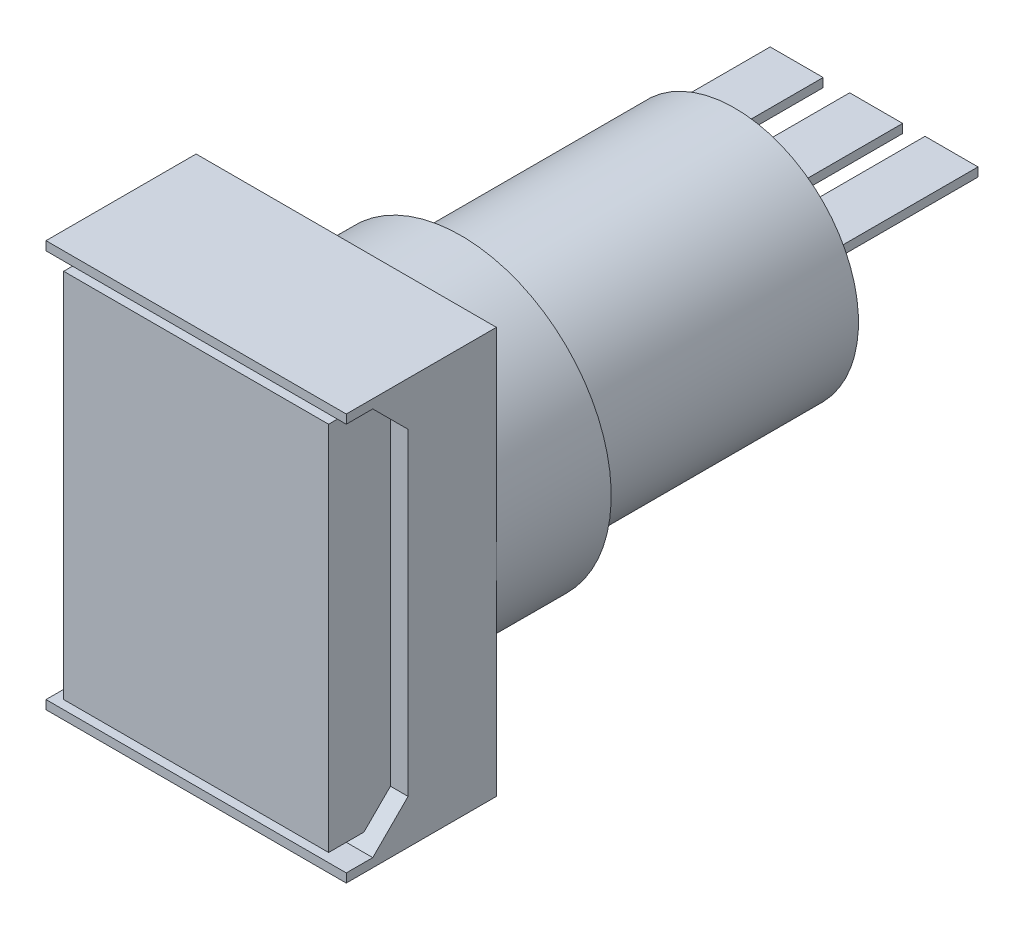
from build123d import *

# Parameters (mm, degrees)
SKETCH_1_W          = 17
SKETCH_1_H          = 23
EXTRUDE_1_DEPTH     = 8.5
CUT_EXTRUDE_1_DEPTH = 20
SKETCH_3_W          = 15
SKETCH_3_H          = 21
EXTRUDE_2_DEPTH     = 3.5
SKETCH_4_R          = 8.5
EXTRUDE_3_DEPTH     = 6.5
SKETCH_5_R          = 7
EXTRUDE_4_DEPTH     = 22
SKETCH_6_W          = 3
SKETCH_6_H          = 0.5
EXTRUDE_5_DEPTH     = 8
SKETCH_7_R          = 6.5
EXTRUDE_6_DEPTH     = 0.01


with BuildPart() as part:
    # ｽｹｯﾁ1 → ﾎﾞｽ - 押し出し1 (new body)
    with BuildSketch(Plane.XY):
        Rectangle(SKETCH_1_W, SKETCH_1_H)
    extrude(amount=EXTRUDE_1_DEPTH)

    # ｽｹｯﾁ2 → ｶｯﾄ - 押し出し1 (cut)
    with BuildSketch(Plane(origin=(8.5, 0, 0), x_dir=(0, 0, -1), z_dir=(1, 0, 0))):
        Polygon((-8.5, 11), (-7, 11), (-5, 9), (-5, -9), (-7, -11), (-8.5, -11), align=None)
    extrude(amount=-CUT_EXTRUDE_1_DEPTH, mode=Mode.SUBTRACT)

    # ｽｹｯﾁ3 → ﾎﾞｽ - 押し出し2 (add)
    with BuildSketch(Plane.XY.offset(5)):
        Rectangle(SKETCH_3_W, SKETCH_3_H)
    extrude(amount=EXTRUDE_2_DEPTH)

    # ｽｹｯﾁ4 → ﾎﾞｽ - 押し出し3 (add)
    with BuildSketch(Plane(origin=(0, 0, 0), x_dir=(-1, 0, 0), z_dir=(0, 0, -1))):
        Circle(SKETCH_4_R)
    extrude(amount=EXTRUDE_3_DEPTH)

    # ｽｹｯﾁ5 → ﾎﾞｽ - 押し出し4 (add)
    with BuildSketch(Plane(origin=(0, 0, 0), x_dir=(-1, 0, 0), z_dir=(0, 0, -1))):
        Circle(SKETCH_5_R)
    extrude(amount=EXTRUDE_4_DEPTH)

    # ｽｹｯﾁ6 → ﾎﾞｽ - 押し出し5 (add)
    with BuildSketch(Plane(origin=(0, 0, -22), x_dir=(-1, 0, 0), z_dir=(0, 0, -1))):
        with Locations((-4.266281297, 2.75)):
            Rectangle(SKETCH_6_W, SKETCH_6_H)
        with Locations((0, 2.75)):
            Rectangle(SKETCH_6_W, SKETCH_6_H)
        with Locations((4.5, 2.75)):
            Rectangle(SKETCH_6_W, SKETCH_6_H)
    extrude(amount=EXTRUDE_5_DEPTH)

    # ｽｹｯﾁ7 → ﾎﾞｽ - 押し出し6 (add)
    with BuildSketch(Plane(origin=(0, 0, -22), x_dir=(-1, 0, 0), z_dir=(0, 0, -1))):
        Circle(SKETCH_7_R)
    extrude(amount=EXTRUDE_6_DEPTH)


solid = part.part
